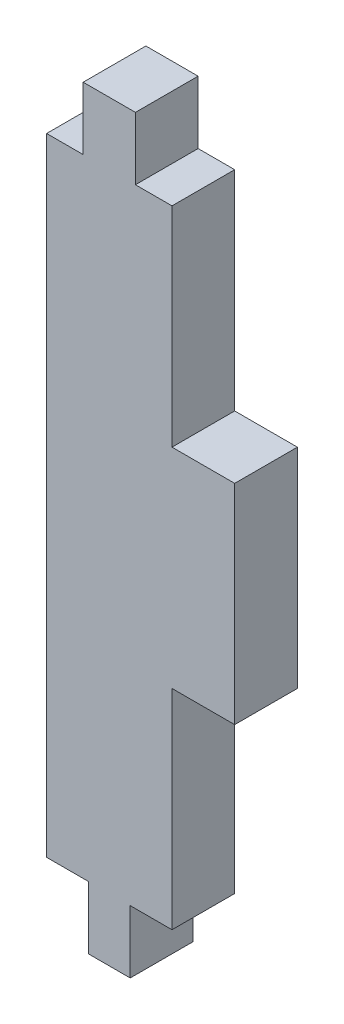
from build123d import *

# Parameters (mm, degrees)
SKETCH1_W           = 4.166666666
SKETCH1_H           = 10
SKETCH1_W_2         = 10
SKETCH1_H_2         = 50
SKETCH1_W_3         = 3.333333334
SKETCH1_W_4         = 5
SKETCH1_H_3         = 16.666666667
BOSS_EXTRUDE1_DEPTH = 5


with BuildPart() as part:
    # Sketch1 → Boss-Extrude1 (new body)
    with BuildSketch(Plane.XY):
        with Locations((-32.230609748, -16.180003411)):
            Rectangle(SKETCH1_W, SKETCH1_H)
        with Locations((-32.230609748, -41.180003411)):
            Rectangle(SKETCH1_W_2, SKETCH1_H_2)
        with Locations((-32.230609748, -66.180003411)):
            Rectangle(SKETCH1_W_3, SKETCH1_H)
        with Locations((-24.730609748, -41.18000341)):
            Rectangle(SKETCH1_W_4, SKETCH1_H_3)
    extrude(amount=BOSS_EXTRUDE1_DEPTH)


solid = part.part
